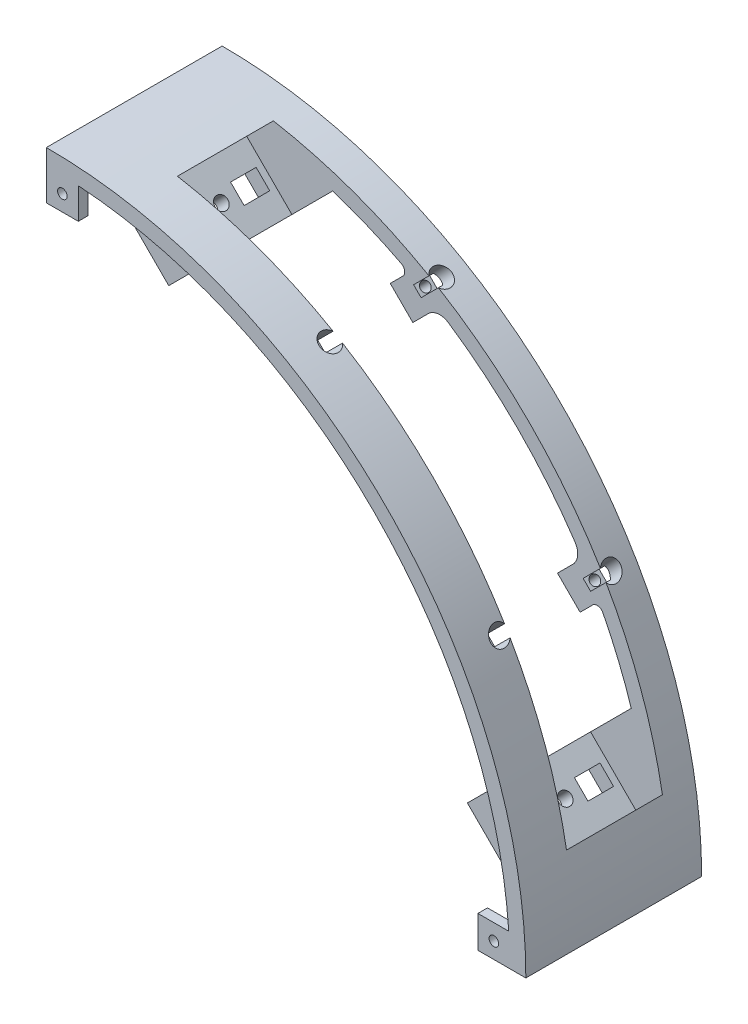
from build123d import *

# Parameters (mm, degrees)
PAROI_DEPTH                    = 55
ESQUISSE11_W                   = 10
ESQUISSE11_H                   = 10
FIXATION_PAROI_BASE_DEPTH      = 3
ESQUISSE13_R                   = 1.5
TROU_FIXATION_PAROI_BASE_DEPTH = 4
EXTRUSION_BUMPER_REACH         = 108.066
ESQUISSE14_W                   = 172.132034356
ESQUISSE14_H                   = 30
BOSS_EXTRU_1_REACH             = 108.066
ESQUISSE15_W                   = 20
ESQUISSE15_H                   = 5
BOSS_EXTRU_2_DEPTH             = 35
ENL_V_MAT_EXTRU_1_REACH        = 108.066
ESQUISSE17_R                   = 2
ESQUISSE18_W                   = 10
ESQUISSE18_H                   = 10
ESQUISSE18_R                   = 1.5
BOSS_EXTRU_3_DEPTH             = 3
ESQUISSE20_W                   = 10
ESQUISSE20_H                   = 6
ESQUISSE20_W_2                 = 6
ESQUISSE20_H_2                 = 8
ENL_V_MAT_EXTRU_2_DEPTH        = 107.066017178
BOSS_EXTRU_4_DEPTH             = 5
BOSS_EXTRU_5_DEPTH             = 5
ENL_V_MAT_EXTRU_3_REACH        = 83.632
ESQUISSE25_R                   = 1.5
ESQUISSE35_R                   = 3
ENL_V_MAT_EXTRU_4_DEPTH        = 12
CONG_1_R                       = 5
CONG_2_R                       = 2


with BuildPart() as part:
    # Esquisse1 → paroi (new body)
    with BuildSketch(Plane.XY):
        with BuildLine():
            Line((0, 150), (0, 145))
            ThreePointArc((0, 145), (102.530483272, 102.530483272), (145, 0))
            Line((145, 0), (150, 0))
            ThreePointArc((150, 0), (106.066017178, 106.066017178), (0, 150))
        make_face()
    extrude(amount=PAROI_DEPTH)

    # Esquisse11 → fixation_paroi_base (add)
    with BuildSketch(Plane(origin=(0, 0, 0), x_dir=(-1, 0, 0), z_dir=(0, 0, -1))):
        with Locations((-140, 5)):
            Rectangle(ESQUISSE11_W, ESQUISSE11_H)
        with Locations((-5, 140)):
            Rectangle(ESQUISSE11_W, ESQUISSE11_H)
    extrude(amount=-FIXATION_PAROI_BASE_DEPTH)

    # Esquisse13 → trou_fixation_paroi_base (cut, through all)
    with BuildSketch(Plane.XY.offset(3)):
        with Locations((5, 140)):
            Circle(ESQUISSE13_R)
        with Locations((140, 5)):
            Circle(ESQUISSE13_R)
    extrude(amount=-TROU_FIXATION_PAROI_BASE_DEPTH, mode=Mode.SUBTRACT)

    # Esquisse14 → extrusion bumper (cut, up to next)
    with BuildSketch(Plane(origin=(75, 75, 0), x_dir=(-0.707106781, 0.707106781, 0), z_dir=(-0.707106781, -0.707106781, 0)), mode=Mode.PRIVATE) as extrusion_bumper_sk1:
        with Locations((0, -25)):
            Rectangle(ESQUISSE14_W, ESQUISSE14_H)
    extrusion_bumper_tool1 = extrude(extrusion_bumper_sk1.sketch, amount=-EXTRUSION_BUMPER_REACH, mode=Mode.PRIVATE) & part.part
    add(extrusion_bumper_tool1.solids().sort_by_distance((75, 75, 25))[0], mode=Mode.SUBTRACT)

    # Esquisse15 → Boss.-Extru.1 (add, up to next)
    with BuildSketch(Plane(origin=(75, 75, 0), x_dir=(-0.707106781, 0.707106781, 0), z_dir=(-0.707106781, -0.707106781, 0)), mode=Mode.PRIVATE) as boss_extru_1_sk1:
        with Locations((76.066017178, -42.5)):
            Rectangle(ESQUISSE15_W, ESQUISSE15_H)
    boss_extru_1_tool1 = extrude(boss_extru_1_sk1.sketch, amount=-BOSS_EXTRU_1_REACH, mode=Mode.PRIVATE) - part.part
    add(boss_extru_1_tool1.solids().sort_by_distance((21.213203, 128.786797, 42.5))[0])
    # Esquisse15 → Boss.-Extru.1 (add, up to next)
    with BuildSketch(Plane(origin=(75, 75, 0), x_dir=(-0.707106781, 0.707106781, 0), z_dir=(-0.707106781, -0.707106781, 0)), mode=Mode.PRIVATE) as boss_extru_1_sk2:
        with Locations((-76.066017178, -42.5)):
            Rectangle(ESQUISSE15_W, ESQUISSE15_H)
    boss_extru_1_tool2 = extrude(boss_extru_1_sk2.sketch, amount=-BOSS_EXTRU_1_REACH, mode=Mode.PRIVATE) - part.part
    add(boss_extru_1_tool2.solids().sort_by_distance((128.786797, 21.213203, 42.5))[0])
    # Esquisse15 → Boss.-Extru.1 (add, up to next)
    with BuildSketch(Plane(origin=(75, 75, 0), x_dir=(-0.707106781, 0.707106781, 0), z_dir=(-0.707106781, -0.707106781, 0)), mode=Mode.PRIVATE) as boss_extru_1_sk3:
        with Locations((76.066017178, -7.5)):
            Rectangle(ESQUISSE15_W, ESQUISSE15_H)
    boss_extru_1_tool3 = extrude(boss_extru_1_sk3.sketch, amount=-BOSS_EXTRU_1_REACH, mode=Mode.PRIVATE) - part.part
    add(boss_extru_1_tool3.solids().sort_by_distance((21.213203, 128.786797, 7.5))[0])
    # Esquisse15 → Boss.-Extru.1 (add, up to next)
    with BuildSketch(Plane(origin=(75, 75, 0), x_dir=(-0.707106781, 0.707106781, 0), z_dir=(-0.707106781, -0.707106781, 0)), mode=Mode.PRIVATE) as boss_extru_1_sk4:
        with Locations((-76.066017178, -7.5)):
            Rectangle(ESQUISSE15_W, ESQUISSE15_H)
    boss_extru_1_tool4 = extrude(boss_extru_1_sk4.sketch, amount=-BOSS_EXTRU_1_REACH, mode=Mode.PRIVATE) - part.part
    add(boss_extru_1_tool4.solids().sort_by_distance((128.786797, 21.213203, 7.5))[0])

    # Esquisse16 → Boss.-Extru.2 (add)
    with BuildSketch(Plane.XY.offset(45)):
        Polygon((135.857864376, 14.142135624), (121.715728753, 28.284271247), (125.251262658, 31.819805153), (139.393398282, 17.67766953), align=None)
        Polygon((28.284271247, 121.715728753), (14.142135624, 135.857864376), (17.67766953, 139.393398282), (31.819805153, 125.251262658), align=None)
    extrude(amount=-BOSS_EXTRU_2_DEPTH)

    # Esquisse17 → Enlèv. mat.-Extru.1 (cut, up to next)
    with BuildSketch(Plane(origin=(75, 75, 0), x_dir=(-0.707106781, 0.707106781, 0), z_dir=(-0.707106781, -0.707106781, 0)), mode=Mode.PRIVATE) as enl_v_mat_extru_1_sk1:
        with Locations((76.066017178, -25)):
            Circle(ESQUISSE17_R)
    enl_v_mat_extru_1_tool1 = extrude(enl_v_mat_extru_1_sk1.sketch, amount=-ENL_V_MAT_EXTRU_1_REACH, mode=Mode.PRIVATE) & part.part
    add(enl_v_mat_extru_1_tool1.solids().sort_by_distance((21.213203, 128.786797, 25))[0], mode=Mode.SUBTRACT)
    # Esquisse17 → Enlèv. mat.-Extru.1 (cut, up to next)
    with BuildSketch(Plane(origin=(75, 75, 0), x_dir=(-0.707106781, 0.707106781, 0), z_dir=(-0.707106781, -0.707106781, 0)), mode=Mode.PRIVATE) as enl_v_mat_extru_1_sk2:
        with Locations((-76.066017178, -25)):
            Circle(ESQUISSE17_R)
    enl_v_mat_extru_1_tool2 = extrude(enl_v_mat_extru_1_sk2.sketch, amount=-ENL_V_MAT_EXTRU_1_REACH, mode=Mode.PRIVATE) & part.part
    add(enl_v_mat_extru_1_tool2.solids().sort_by_distance((128.786797, 21.213203, 25))[0], mode=Mode.SUBTRACT)

    # Esquisse18 → Boss.-Extru.3 (add)
    with BuildSketch(Plane.XY.offset(55)):
        with Locations((5, 140)):
            Rectangle(ESQUISSE18_W, ESQUISSE18_H)
        with Locations((5, 140)):
            Circle(ESQUISSE18_R, mode=Mode.SUBTRACT)
        with Locations((140, 5)):
            Rectangle(ESQUISSE18_W, ESQUISSE18_H)
        with Locations((140, 5)):
            Circle(ESQUISSE18_R, mode=Mode.SUBTRACT)
    extrude(amount=-BOSS_EXTRU_3_DEPTH)

    # Esquisse20 → Enlèv. mat.-Extru.2 (cut, through all)
    with BuildSketch(Plane(origin=(75, 75, 0), x_dir=(-0.707106781, 0.707106781, 0), z_dir=(-0.707106781, -0.707106781, 0))):
        with Locations((76.066017178, -34)):
            Rectangle(ESQUISSE20_W, ESQUISSE20_H)
        with Locations((76.066017178, -16)):
            Rectangle(ESQUISSE20_W_2, ESQUISSE20_H_2)
        with Locations((-76.066017178, -34)):
            Rectangle(ESQUISSE20_W, ESQUISSE20_H)
        with Locations((-76.066017178, -16)):
            Rectangle(ESQUISSE20_W_2, ESQUISSE20_H_2)
    extrude(amount=-ENL_V_MAT_EXTRU_2_DEPTH, mode=Mode.SUBTRACT)

    # Esquisse21 → Boss.-Extru.4 (add)
    with BuildSketch(Plane.XY.offset(45)):
        Polygon((71.4177849, 130.81475452), (78.488852712, 123.743686708), (69.650017947, 114.904851943), (62.578950135, 121.975919755), align=None)
        Polygon((130.81475452, 71.4177849), (123.743686708, 78.488852712), (114.904851943, 69.650017947), (121.975919755, 62.578950135), align=None)
    extrude(amount=-BOSS_EXTRU_4_DEPTH)

    # Esquisse24 → Boss.-Extru.5 (add)
    with BuildSketch(Plane.XY.offset(10)):
        Polygon((62.578950135, 121.975919755), (71.065878403, 130.462848023), (78.136946215, 123.391780211), (69.650017947, 114.904851943), align=None)
        Polygon((121.975919755, 62.578950135), (130.462848023, 71.065878403), (123.391780211, 78.136946215), (114.904851943, 69.650017947), align=None)
    extrude(amount=-BOSS_EXTRU_5_DEPTH)

    # Esquisse25 → Enlèv. mat.-Extru.3 (cut, up to next)
    with BuildSketch(Plane(origin=(92.277434945, 92.277434945, 0), x_dir=(0, 0, 1), z_dir=(-0.707106781, -0.707106781, 0)), mode=Mode.PRIVATE) as enl_v_mat_extru_3_sk1:
        with Locations((42.5, 37.5)):
            Circle(ESQUISSE25_R)
    enl_v_mat_extru_3_tool1 = extrude(enl_v_mat_extru_3_sk1.sketch, amount=-ENL_V_MAT_EXTRU_3_REACH, mode=Mode.PRIVATE) & part.part
    add(enl_v_mat_extru_3_tool1.solids().sort_by_distance((65.760931, 118.793939, 42.5))[0], mode=Mode.SUBTRACT)
    # Esquisse25 → Enlèv. mat.-Extru.3 (cut, up to next)
    with BuildSketch(Plane(origin=(92.277434945, 92.277434945, 0), x_dir=(0, 0, 1), z_dir=(-0.707106781, -0.707106781, 0)), mode=Mode.PRIVATE) as enl_v_mat_extru_3_sk2:
        with Locations((42.5, -37.5)):
            Circle(ESQUISSE25_R)
    enl_v_mat_extru_3_tool2 = extrude(enl_v_mat_extru_3_sk2.sketch, amount=-ENL_V_MAT_EXTRU_3_REACH, mode=Mode.PRIVATE) & part.part
    add(enl_v_mat_extru_3_tool2.solids().sort_by_distance((118.793939, 65.760931, 42.5))[0], mode=Mode.SUBTRACT)
    # Esquisse25 → Enlèv. mat.-Extru.3 (cut, up to next)
    with BuildSketch(Plane(origin=(92.277434945, 92.277434945, 0), x_dir=(0, 0, 1), z_dir=(-0.707106781, -0.707106781, 0)), mode=Mode.PRIVATE) as enl_v_mat_extru_3_sk3:
        with Locations((7.5, 37.5)):
            Circle(ESQUISSE25_R)
    enl_v_mat_extru_3_tool3 = extrude(enl_v_mat_extru_3_sk3.sketch, amount=-ENL_V_MAT_EXTRU_3_REACH, mode=Mode.PRIVATE) & part.part
    add(enl_v_mat_extru_3_tool3.solids().sort_by_distance((65.760931, 118.793939, 7.5))[0], mode=Mode.SUBTRACT)
    # Esquisse25 → Enlèv. mat.-Extru.3 (cut, up to next)
    with BuildSketch(Plane(origin=(92.277434945, 92.277434945, 0), x_dir=(0, 0, 1), z_dir=(-0.707106781, -0.707106781, 0)), mode=Mode.PRIVATE) as enl_v_mat_extru_3_sk4:
        with Locations((7.5, -37.5)):
            Circle(ESQUISSE25_R)
    enl_v_mat_extru_3_tool4 = extrude(enl_v_mat_extru_3_sk4.sketch, amount=-ENL_V_MAT_EXTRU_3_REACH, mode=Mode.PRIVATE) & part.part
    add(enl_v_mat_extru_3_tool4.solids().sort_by_distance((118.793939, 65.760931, 7.5))[0], mode=Mode.SUBTRACT)

    # Esquisse35 → Enlèv. mat.-Extru.4 (cut)
    with BuildSketch(Plane(origin=(106.066017178, 106.066017178, 0), x_dir=(0, 0, 1), z_dir=(-0.707106781, -0.707106781, 0))):
        with Locations((42.5, -37.5)):
            Circle(ESQUISSE35_R)
        with Locations((42.5, 37.5)):
            Circle(ESQUISSE35_R)
        with Locations((7.5, -37.5)):
            Circle(ESQUISSE35_R)
        with Locations((7.5, 37.5)):
            Circle(ESQUISSE35_R)
    extrude(amount=ENL_V_MAT_EXTRU_4_DEPTH, mode=Mode.SUBTRACT)

    # Congé1
    cong_1_edges = [part.edges().sort_by_distance(p)[0] for p in [
        (77.375082971, 122.629916967, 42.5),
        (122.629916967, 77.375082971, 42.5),
        (77.375082971, 122.629916967, 7.5),
        (122.629916967, 77.375082971, 7.5),
    ]]
    fillet(cong_1_edges, radius=CONG_1_R)

    # Congé2
    cong_2_edges = [part.edges().sort_by_distance(p)[0] for p in [
        (68.436626134, 127.833595754, 42.5),
        (127.833595754, 68.436626134, 42.5),
        (68.436626134, 127.833595754, 7.5),
        (127.833595754, 68.436626134, 7.5),
    ]]
    fillet(cong_2_edges, radius=CONG_2_R)


solid = part.part
